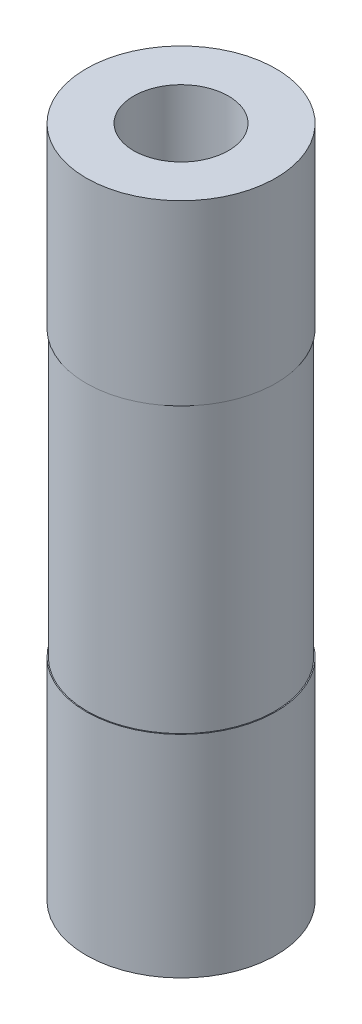
from build123d import *

# Parameters (mm, degrees)
CROQUIS1_R              = 10
SALIENTE_EXTRUIR1_DEPTH = 71
CROQUIS2_R              = 5
CORTAR_EXTRUIR1_DEPTH   = 72
CROQUIS3_W              = 0.1
CROQUIS3_H              = 30


with BuildPart() as part:
    # Croquis1 → Saliente-Extruir1 (new body)
    with BuildSketch(Plane(origin=(0, 0, 0), x_dir=(1, 0, 0), z_dir=(0, 1, 0))):
        Circle(CROQUIS1_R)
    extrude(amount=SALIENTE_EXTRUIR1_DEPTH)

    # Croquis2 → Cortar-Extruir1 (cut, through all)
    with BuildSketch(Plane(origin=(0, 71, 0), x_dir=(1, 0, 0), z_dir=(0, 1, 0))):
        Circle(CROQUIS2_R)
    extrude(amount=-CORTAR_EXTRUIR1_DEPTH, mode=Mode.SUBTRACT)

    # Croquis3 → Cortar-Revolución1 (revolve, cut)
    with BuildSketch(Plane(origin=(0, 0, 0), x_dir=(0, 0, -1), z_dir=(1, 0, 0))):
        with Locations((9.95, 37.25)):
            Rectangle(CROQUIS3_W, CROQUIS3_H)
    revolve(axis=Axis((0, 71, 0), (0, -1, 0)), mode=Mode.SUBTRACT)


solid = part.part
